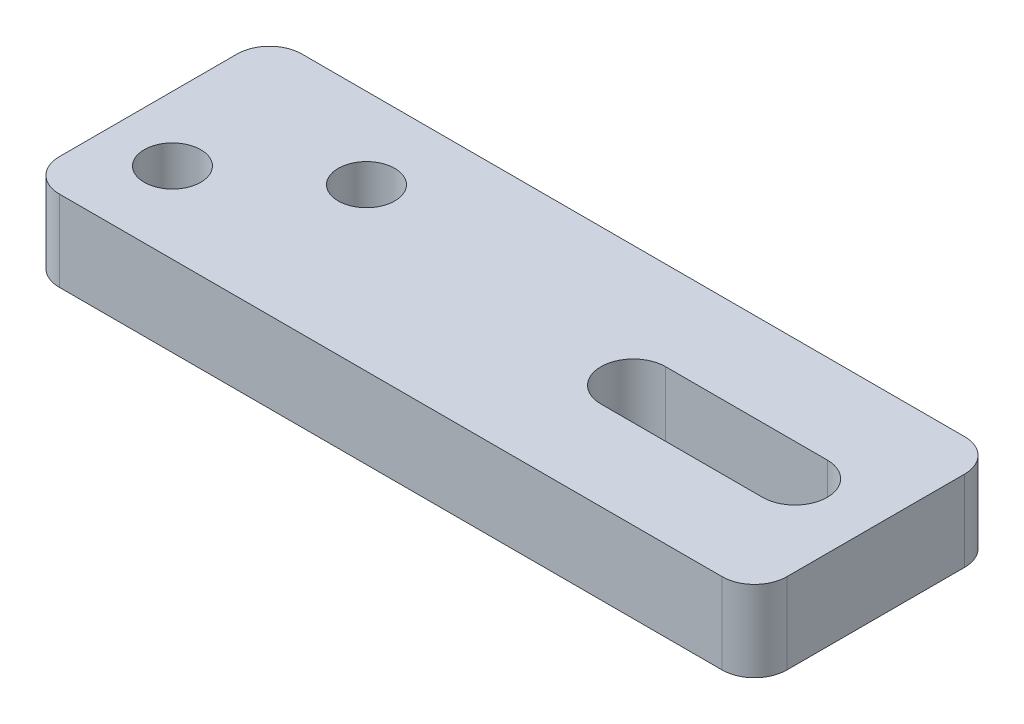
from build123d import *

# Parameters (mm, degrees)
SKETCH_1_R      = 1.75
EXTRUDE_1_DEPTH = 5


with BuildPart() as part:
    # 草图1 → 凸台-拉伸1 (new body)
    with BuildSketch(Plane(origin=(0, 0, 0), x_dir=(1, 0, 0), z_dir=(0, 1, 0))):
        with BuildLine():
            Line((0, 5.5), (0, -5.5))
            ThreePointArc((0, -5.5), (0.585786438, -6.914213562), (2, -7.5))
            Line((2, -7.5), (43, -7.5))
            ThreePointArc((43, -7.5), (44.414213562, -6.914213562), (45, -5.5))
            Line((45, -5.5), (45, 5.5))
            ThreePointArc((45, 5.5), (44.414213562, 6.914213562), (43, 7.5))
            Line((43, 7.5), (2, 7.5))
            ThreePointArc((2, 7.5), (0.585786438, 6.914213562), (0, 5.5))
        make_face()
        with Locations((4, -2.5)):
            Circle(SKETCH_1_R, mode=Mode.SUBTRACT)
        with Locations((11, 2.5)):
            Circle(SKETCH_1_R, mode=Mode.SUBTRACT)
        with BuildLine():
            Line((30.028060952, -2), (40, -2))
            ThreePointArc((40, -2), (42, 3.9373e-05), (40, 2))
            Line((40, 2), (29.99998029, 1.999803136))
            ThreePointArc((29.99998029, 1.999803136), (28.000049288, -0.014237539), (30.028060952, -2))
        make_face(mode=Mode.SUBTRACT)
    extrude(amount=EXTRUDE_1_DEPTH)


solid = part.part
